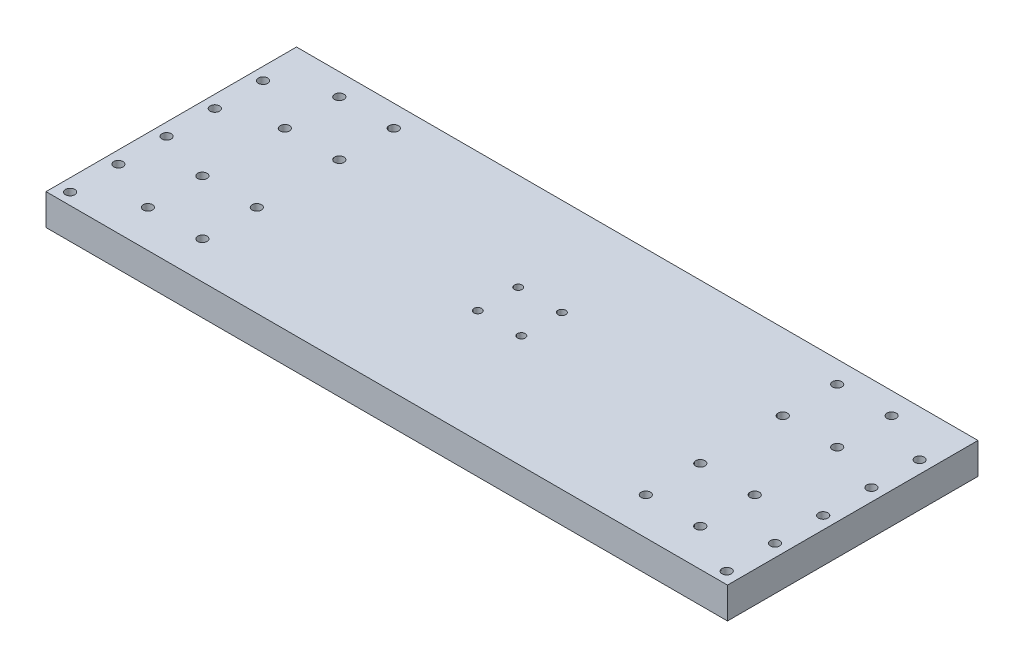
from build123d import *

# Parameters (mm, degrees)
ESQUISSE1_W             = 438
ESQUISSE1_H             = 161
ESQUISSE1_R             = 3
ESQUISSE1_R_2           = 2.5
BOSS_EXTRU_1_DEPTH      = 10
BOSS_EXTRU_1_DEPTH_BACK = 10
ESQUISSE2_R             = 2.5
ENL_V_MAT_EXTRU_1_DEPTH = 20


with BuildPart() as part:
    # Esquisse1 → Boss.-Extru.1 (new body, two sides)
    with BuildSketch(Plane(origin=(0, 0, 0), x_dir=(1, 0, 0), z_dir=(0, 1, 0))) as boss_extru_1_sk:
        with Locations((0, -5)):
            Rectangle(ESQUISSE1_W, ESQUISSE1_H)
        with Locations(Location((177.5, -61.5, 0), (0, 0, 270))):  # turned: the seam where the file's is
            Circle(ESQUISSE1_R, mode=Mode.SUBTRACT)
        with Locations(Location((177.5, -26.5, 0), (0, 0, 270))):  # turned: the seam where the file's is
            Circle(ESQUISSE1_R, mode=Mode.SUBTRACT)
        with Locations(Location((142.5, -26.5, 0), (0, 0, 270))):  # turned: the seam where the file's is
            Circle(ESQUISSE1_R, mode=Mode.SUBTRACT)
        with Locations(Location((142.5, -61.5, 0), (0, 0, 270))):  # turned: the seam where the file's is
            Circle(ESQUISSE1_R, mode=Mode.SUBTRACT)
        with Locations(Location((142.5, 26.5, 0), (0, 0, 270))):  # turned: the seam where the file's is
            Circle(ESQUISSE1_R, mode=Mode.SUBTRACT)
        with Locations(Location((142.5, 61.5, 0), (0, 0, 270))):  # turned: the seam where the file's is
            Circle(ESQUISSE1_R, mode=Mode.SUBTRACT)
        with Locations(Location((177.5, 61.5, 0), (0, 0, 270))):  # turned: the seam where the file's is
            Circle(ESQUISSE1_R, mode=Mode.SUBTRACT)
        with Locations(Location((177.5, 26.5, 0), (0, 0, 270))):  # turned: the seam where the file's is
            Circle(ESQUISSE1_R, mode=Mode.SUBTRACT)
        with Locations(Location((-142.5, 61.5, 0), (0, 0, 270))):  # turned: the seam where the file's is
            Circle(ESQUISSE1_R, mode=Mode.SUBTRACT)
        with Locations(Location((-177.5, 61.5, 0), (0, 0, 270))):  # turned: the seam where the file's is
            Circle(ESQUISSE1_R, mode=Mode.SUBTRACT)
        with Locations(Location((-177.5, 26.5, 0), (0, 0, 270))):  # turned: the seam where the file's is
            Circle(ESQUISSE1_R, mode=Mode.SUBTRACT)
        with Locations(Location((-142.5, 26.5, 0), (0, 0, 270))):  # turned: the seam where the file's is
            Circle(ESQUISSE1_R, mode=Mode.SUBTRACT)
        with Locations(Location((-142.5, -26.5, 0), (0, 0, 270))):  # turned: the seam where the file's is
            Circle(ESQUISSE1_R, mode=Mode.SUBTRACT)
        with Locations(Location((-177.5, -26.5, 0), (0, 0, 270))):  # turned: the seam where the file's is
            Circle(ESQUISSE1_R, mode=Mode.SUBTRACT)
        with Locations(Location((-177.5, -61.5, 0), (0, 0, 270))):  # turned: the seam where the file's is
            Circle(ESQUISSE1_R, mode=Mode.SUBTRACT)
        with Locations(Location((-142.5, -61.5, 0), (0, 0, 270))):  # turned: the seam where the file's is
            Circle(ESQUISSE1_R, mode=Mode.SUBTRACT)
        with Locations(Location((14, 13, 0), (0, 0, 270))):  # turned: the seam where the file's is
            Circle(ESQUISSE1_R_2, mode=Mode.SUBTRACT)
        with Locations(Location((-14, 13, 0), (0, 0, 270))):  # turned: the seam where the file's is
            Circle(ESQUISSE1_R_2, mode=Mode.SUBTRACT)
        with Locations(Location((-14, -13, 0), (0, 0, 270))):  # turned: the seam where the file's is
            Circle(ESQUISSE1_R_2, mode=Mode.SUBTRACT)
        with Locations(Location((14, -13, 0), (0, 0, 270))):  # turned: the seam where the file's is
            Circle(ESQUISSE1_R_2, mode=Mode.SUBTRACT)
        with Locations(Location((211, -78, 0), (0, 0, 270))):  # turned: the seam where the file's is
            Circle(ESQUISSE1_R, mode=Mode.SUBTRACT)
        with Locations(Location((211, 46, 0), (0, 0, 270))):  # turned: the seam where the file's is
            Circle(ESQUISSE1_R, mode=Mode.SUBTRACT)
        with Locations(Location((211, -16, 0), (0, 0, 270))):  # turned: the seam where the file's is
            Circle(ESQUISSE1_R, mode=Mode.SUBTRACT)
        with Locations(Location((211, 15, 0), (0, 0, 270))):  # turned: the seam where the file's is
            Circle(ESQUISSE1_R, mode=Mode.SUBTRACT)
        with Locations(Location((211, -47, 0), (0, 0, 270))):  # turned: the seam where the file's is
            Circle(ESQUISSE1_R, mode=Mode.SUBTRACT)
        with Locations(Location((-211, 46, 0), (0, 0, 270))):  # turned: the seam where the file's is
            Circle(ESQUISSE1_R, mode=Mode.SUBTRACT)
        with Locations(Location((-211, -16, 0), (0, 0, 270))):  # turned: the seam where the file's is
            Circle(ESQUISSE1_R, mode=Mode.SUBTRACT)
        with Locations(Location((-211, 15, 0), (0, 0, 270))):  # turned: the seam where the file's is
            Circle(ESQUISSE1_R, mode=Mode.SUBTRACT)
        with Locations(Location((-211, -47, 0), (0, 0, 270))):  # turned: the seam where the file's is
            Circle(ESQUISSE1_R, mode=Mode.SUBTRACT)
        with Locations(Location((-211, -78, 0), (0, 0, 270))):  # turned: the seam where the file's is
            Circle(ESQUISSE1_R, mode=Mode.SUBTRACT)
    extrude(amount=BOSS_EXTRU_1_DEPTH)
    extrude(boss_extru_1_sk.sketch, amount=-BOSS_EXTRU_1_DEPTH_BACK)

    # Esquisse2 → Enl_v. mat.-Extru.1 (cut)
    with BuildSketch(Plane(origin=(0, 0, -75.5), x_dir=(-1, 0, 0), z_dir=(0, 0, -1))):
        with Locations((-206, 0)):
            Circle(ESQUISSE2_R)
        Circle(ESQUISSE2_R)
        with Locations((-103, 0)):
            Circle(ESQUISSE2_R)
        with Locations((-154.5, 0)):
            Circle(ESQUISSE2_R)
        with Locations((-51.5, 0)):
            Circle(ESQUISSE2_R)
        with Locations((51.5, 0)):
            Circle(ESQUISSE2_R)
        with Locations((103, 0)):
            Circle(ESQUISSE2_R)
        with Locations((154.5, 0)):
            Circle(ESQUISSE2_R)
        with Locations((206, 0)):
            Circle(ESQUISSE2_R)
    extrude(amount=-ENL_V_MAT_EXTRU_1_DEPTH, mode=Mode.SUBTRACT)


solid = part.part
